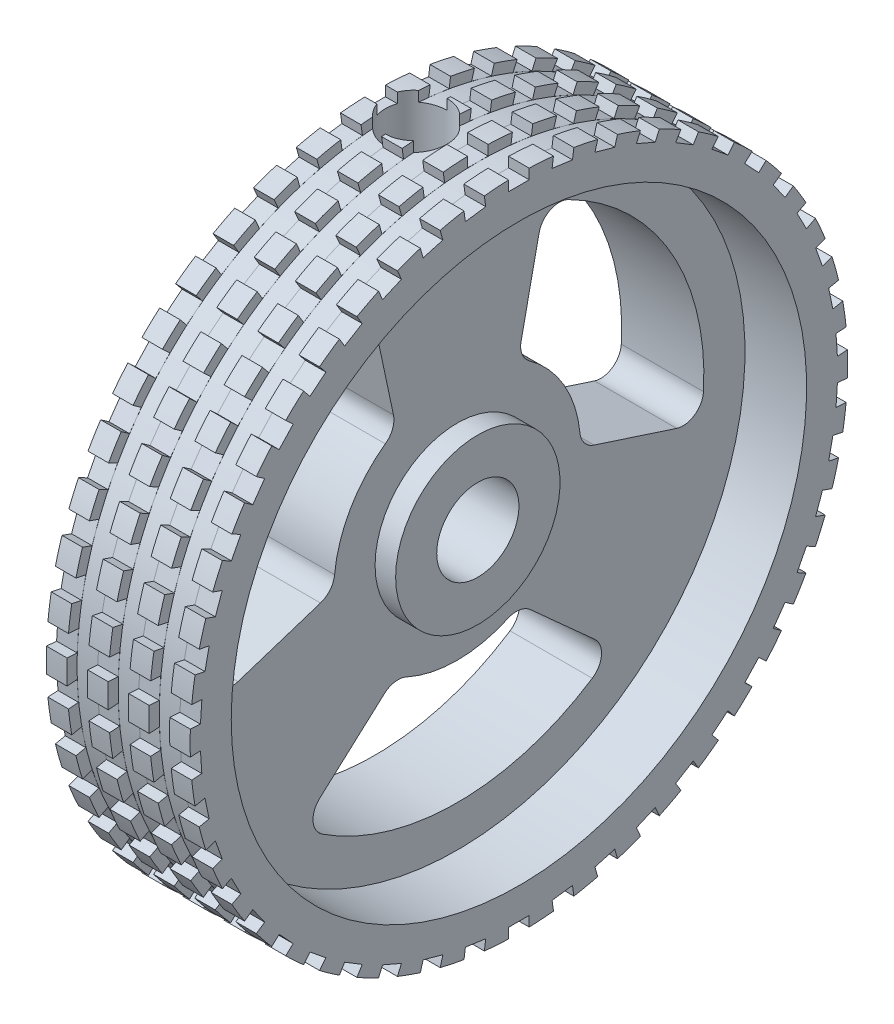
from build123d import *

# Parameters (mm, degrees)
CUT_EXTRUDE2_DEPTH       = 5.0000001
FILLET2_R                = 1
CIRPATTERN2_COUNT        = 3
FILLET2_OF_CIRPATTERN2_R = 1
SKETCH5_W                = 1
SKETCH5_H                = 0.5
SKETCH8_W                = 1
SKETCH8_H                = 0.5
CUT_EXTRUDE4_DEPTH       = 10
CIRPATTERN3_COUNT        = 46
LPATTERN1_COUNT          = 3
LPATTERN1_PITCH          = 2


with BuildPart() as part:
    # Sketch1 → Revolve1 (revolve)
    with BuildSketch(Plane.XY):
        Polygon((0, 2), (0, 16), (7, 16), (7, 14), (4, 14), (4, 4), (5, 4), (5, 2), align=None)
    revolve(axis=Axis((0, 0, 0), (1, 0, 0)))

    # Sketch2 → Cut-Revolve1 (revolve, cut)
    with BuildSketch(Plane.XY):
        Polygon((2, 0), (2.9, 0), (2.9, 11.5), (3.5, 11.5), (3.5, 16), (2, 16), align=None)
    revolve(axis=Axis((2, 16, 0), (0, -1, 0)), mode=Mode.SUBTRACT)

    # Sketch4 → Cut-Extrude2 (cut, through all)
    with BuildSketch(Plane(origin=(4, 0, 0), x_dir=(0, 0, -1), z_dir=(1, 0, 0))):
        with BuildLine():
            Line((-4.23916209, 11.22628633), (-2.962037201, 5.217886125))
            ThreePointArc((-2.962037201, 5.217886125), (-5.196152423, 3), (-5.999840539, -0.043743599))
            Line((-5.999840539, -0.043743599), (-11.841830197, -1.941921104))
            ThreePointArc((-11.841830197, -1.941921104), (-10.392304845, 6), (-4.23916209, 11.22628633))
        make_face()
    cut_extrude2 = extrude(amount=-CUT_EXTRUDE2_DEPTH, mode=Mode.SUBTRACT)

    # Fillet2
    fillet2_edges = [part.edges().sort_by_distance(p)[0] for p in [
        (2, 5.217886125, 2.962037201),
        (2, -0.043743599, 5.999840539),
        (2, -1.941921104, 11.841830197),
        (2, 11.22628633, 4.23916209),
    ]]
    fillet(fillet2_edges, radius=FILLET2_R)

    # CirPattern2: Cut-Extrude2 ×3 about axis
    cirpattern2_axis = Axis((0, 0, 0), (1, 0, 0))
    for i in range(1, CIRPATTERN2_COUNT):
        add(cut_extrude2.rotate(cirpattern2_axis, i * 360 / CIRPATTERN2_COUNT), mode=Mode.SUBTRACT)

    # Fillet2 of CirPattern2
    fillet2_of_cirpattern2_edges = [part.edges().sort_by_distance(p)[0] for p in [
        (2, -5.174142526, 3.037803338),
        (2, -5.174142526, -3.037803338),
        (2, -9.284365226, -7.602668107),
        (2, -9.284365226, 7.602668107),
        (2, -0.043743599, -5.999840539),
        (2, 5.217886125, -2.962037201),
        (2, 11.22628633, -4.23916209),
        (2, -1.941921104, -11.841830197),
    ]]
    fillet(fillet2_of_cirpattern2_edges, radius=FILLET2_OF_CIRPATTERN2_R)

    # Sketch5 → Cut-Revolve2 (revolve, cut)
    with BuildSketch(Plane.XY):
        with Locations((5.5, 15.75)):
            Rectangle(SKETCH5_W, SKETCH5_H)
    cut_revolve2 = revolve(axis=Axis((0, 0, 0), (1, 0, 0)), mode=Mode.SUBTRACT)

    # Sketch8 → Cut-Extrude4 (cut)
    with BuildSketch(Plane.ZY):
        with Locations((0, 15.75)):
            Rectangle(SKETCH8_W, SKETCH8_H)
    cut_extrude4 = extrude(amount=-CUT_EXTRUDE4_DEPTH, mode=Mode.SUBTRACT)

    # CirPattern3: Cut-Revolve2, Cut-Extrude4 ×46 about axis
    cirpattern3_axis = Axis((0, 0, 0), (1, 0, 0))
    for i in range(1, CIRPATTERN3_COUNT):
        add(cut_revolve2.rotate(cirpattern3_axis, i * 360 / CIRPATTERN3_COUNT), mode=Mode.SUBTRACT)
        add(cut_extrude4.rotate(cirpattern3_axis, i * 360 / CIRPATTERN3_COUNT), mode=Mode.SUBTRACT)

    # LPattern1: Cut-Revolve2 ×3
    with Locations(*[(-i * LPATTERN1_PITCH, 0, 0) for i in range(1, LPATTERN1_COUNT)]):
        add(cut_revolve2, mode=Mode.SUBTRACT)


solid = part.part
